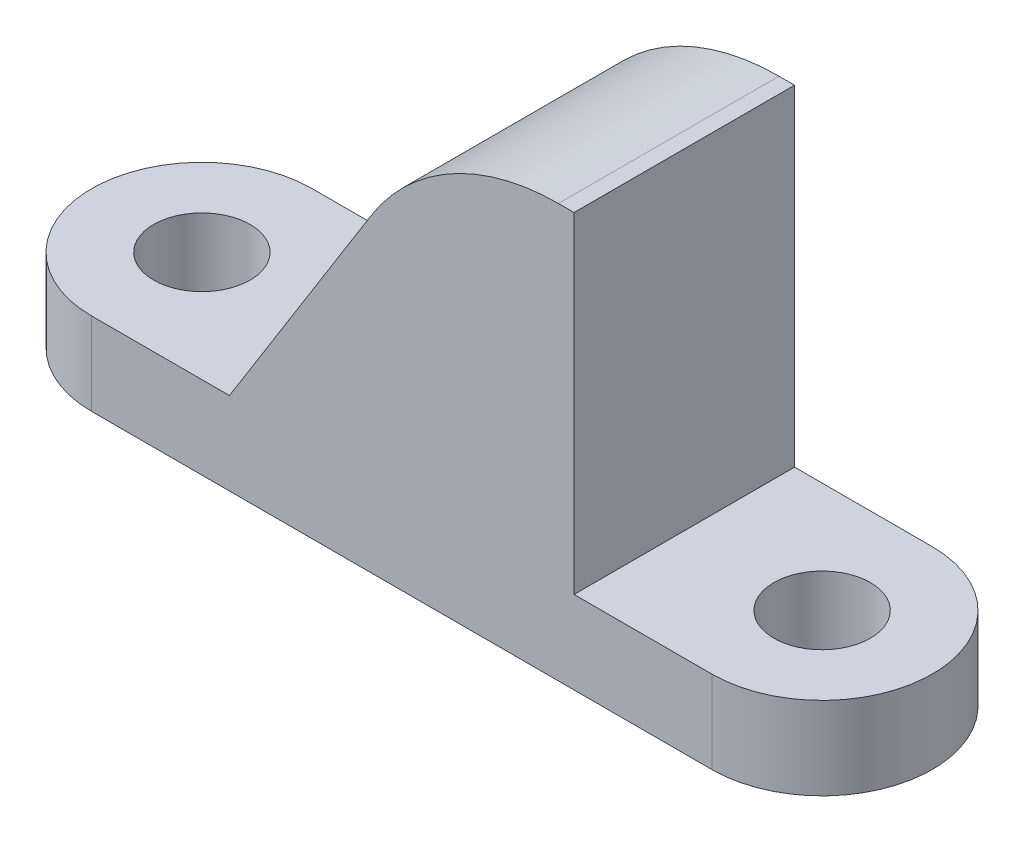
from build123d import *

# Parameters (mm, degrees)
SKETCH1_R           = 1.75
BOSS_EXTRUDE1_DEPTH = 3
SKETCH2_W           = 5
SKETCH2_H           = 8
BOSS_EXTRUDE2_DEPTH = 12
BOSS_EXTRUDE3_DEPTH = 8
FILLET2_R           = 8


with BuildPart() as part:
    # Sketch1 → Boss-Extrude1 (new body)
    with BuildSketch(Plane(origin=(0, 0, 0), x_dir=(1, 0, 0), z_dir=(0, 1, 0))):
        with BuildLine():
            Line((-11.25, -4), (11.25, -4))
            ThreePointArc((11.25, -4), (15.25, 0), (11.25, 4))
            Line((11.25, 4), (-11.25, 4))
            ThreePointArc((-11.25, 4), (-15.25, 0), (-11.25, -4))
        make_face()
        with Locations((-11.25, 0)):
            Circle(SKETCH1_R, mode=Mode.SUBTRACT)
        with Locations((11.25, 0)):
            Circle(SKETCH1_R, mode=Mode.SUBTRACT)
    extrude(amount=BOSS_EXTRUDE1_DEPTH)

    # Sketch2 → Boss-Extrude2 (add)
    with BuildSketch(Plane(origin=(0, 3, 0), x_dir=(1, 0, 0), z_dir=(0, 1, 0))):
        with Locations((3.75, 0)):
            Rectangle(SKETCH2_W, SKETCH2_H)
    extrude(amount=BOSS_EXTRUDE2_DEPTH)

    # Sketch3 → Boss-Extrude3 (add)
    with BuildSketch(Plane.XY.offset(4)):
        Polygon((1.25, 15), (-6.25, 3), (1.25, 3), align=None)
    extrude(amount=-BOSS_EXTRUDE3_DEPTH)

    # Fillet2
    fillet2_edges = [part.edges().sort_by_distance(p)[0] for p in [
        (1.25, 15, 0),
    ]]
    fillet(fillet2_edges, radius=FILLET2_R)


solid = part.part
